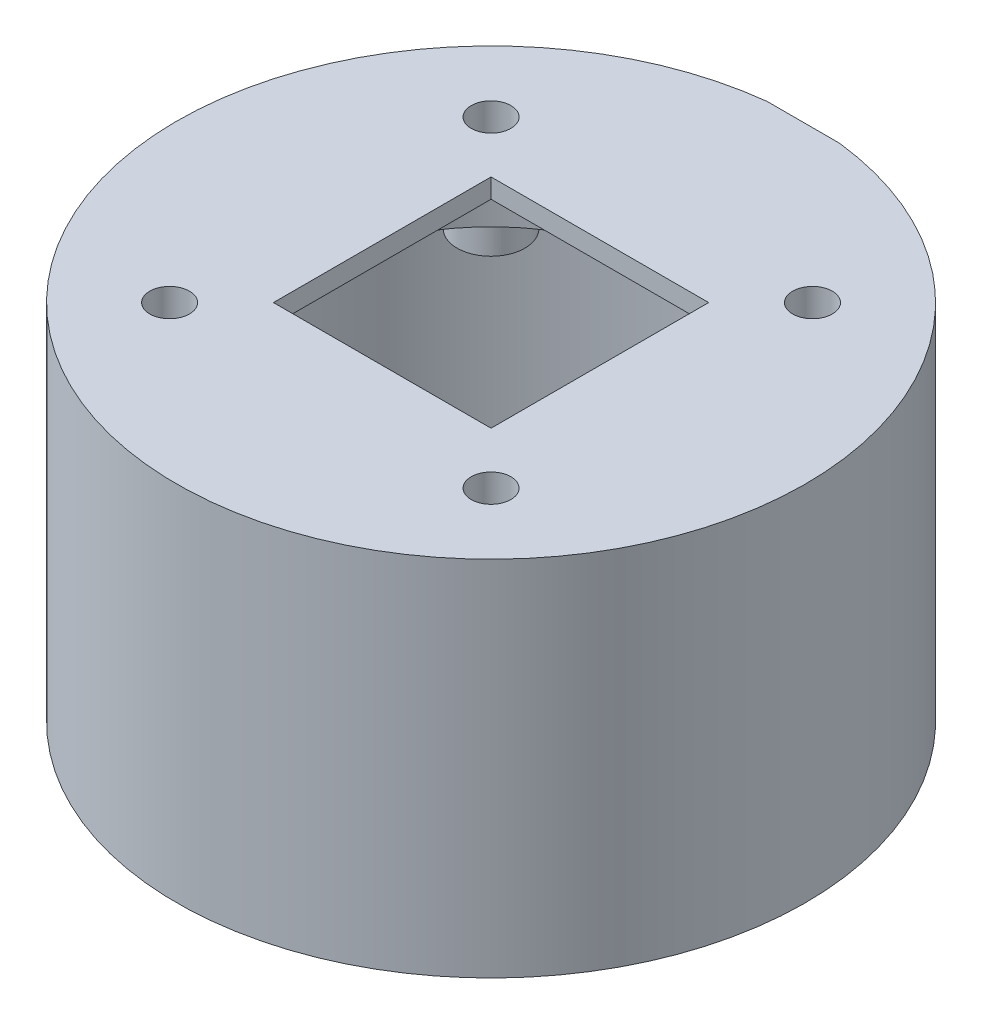
from build123d import *

# Parameters (mm, degrees)
SKETCH1_R               = 65
SKETCH1_R_2             = 60
BOSS_EXTRUDE1_DEPTH     = 55
SKETCH2_R               = 65
BOSS_EXTRUDE2_DEPTH     = 20
SKETCH3_R               = 4.1
SKETCH3_W               = 45
SKETCH3_H               = 45
CUT_EXTRUDE1_DEPTH      = 76
SKETCH5_W               = 45
SKETCH5_H               = 20
CUT_EXTRUDE2_DEPTH      = 18
SKETCH6_R               = 51
CUT_EXTRUDE3_DEPTH      = 6
SKETCH7_R               = 7
SKETCH7_R_2             = 4.1
BOSS_EXTRUDE3_DEPTH     = 6
SKETCH8_R               = 39
CUT_EXTRUDE4_DEPTH      = 10
CUT_EXTRUDE5_DEPTH      = 1
CUT_EXTRUDE5_DEPTH_BACK = 76
SKETCH10_W              = 15
SKETCH10_H              = 12.8
CUT_EXTRUDE6_DEPTH      = 10
CUT_EXTRUDE7_START      = -3
SKETCH11_W              = 20
SKETCH11_H              = 20
CUT_EXTRUDE7_DEPTH      = 10
SKETCH12_R              = 7.5
CUT_EXTRUDE8_DEPTH      = 6
SKETCH13_R              = 10.5
CUT_EXTRUDE9_DEPTH      = 56
CUT_EXTRUDE9_DEPTH_BACK = 6


with BuildPart() as part:
    # Sketch1 → Boss-Extrude1 (new body)
    with BuildSketch(Plane(origin=(0, 0, 0), x_dir=(1, 0, 0), z_dir=(0, 1, 0))):
        with Locations(Location((0, 0, 0), (0, 0, 270))):  # turned: the seam where the file's is
            Circle(SKETCH1_R)
        with Locations(Location((0, 0, 0), (0, 0, 270))):  # turned: the seam where the file's is
            Circle(SKETCH1_R_2, mode=Mode.SUBTRACT)
    extrude(amount=BOSS_EXTRUDE1_DEPTH)

    # Sketch2 → Boss-Extrude2 (add)
    with BuildSketch(Plane(origin=(0, 55, 0), x_dir=(1, 0, 0), z_dir=(0, 1, 0))):
        with Locations(Location((0, 0, 0), (0, 0, 270))):  # turned: the seam where the file's is
            Circle(SKETCH2_R)
    extrude(amount=BOSS_EXTRUDE2_DEPTH)

    # Sketch3 → Cut-Extrude1 (cut, through all)
    with BuildSketch(Plane(origin=(0, 75, 0), x_dir=(1, 0, 0), z_dir=(0, 1, 0))):
        with Locations(Location((-33.234018716, -33.234018716, 0), (0, 0, 270))):  # turned: the seam where the file's is
            Circle(SKETCH3_R)
        with Locations(Location((-33.234018716, 33.234018716, 0), (0, 0, 270))):  # turned: the seam where the file's is
            Circle(SKETCH3_R)
        with Locations(Location((33.234018716, 33.234018716, 0), (0, 0, 270))):  # turned: the seam where the file's is
            Circle(SKETCH3_R)
        with Locations(Location((33.234018716, -33.234018716, 0), (0, 0, 270))):  # turned: the seam where the file's is
            Circle(SKETCH3_R)
        Rectangle(SKETCH3_W, SKETCH3_H)
    extrude(amount=-CUT_EXTRUDE1_DEPTH, mode=Mode.SUBTRACT)

    # Sketch5 → Cut-Extrude2 (cut)
    with BuildSketch(Plane.XZ.offset(-55)):
        with Locations((0, 32.5)):
            Rectangle(SKETCH5_W, SKETCH5_H)
    extrude(amount=-CUT_EXTRUDE2_DEPTH, mode=Mode.SUBTRACT)

    # Sketch6 → Cut-Extrude3 (cut)
    with BuildSketch(Plane.XZ.offset(-55)):
        Circle(SKETCH6_R)
    extrude(amount=-CUT_EXTRUDE3_DEPTH, mode=Mode.SUBTRACT)

    # Sketch7 → Boss-Extrude3 (add)
    with BuildSketch(Plane.XZ.offset(-61)):
        with Locations((-33.234018716, -33.234018716)):
            Circle(SKETCH7_R)
        with Locations(Location((-33.234018716, -33.234018716, 0), (0, 0, 90))):  # turned: the seam where the file's is
            Circle(SKETCH7_R_2, mode=Mode.SUBTRACT)
        with Locations((-33.234018716, 33.234018716)):
            Circle(SKETCH7_R)
        with Locations(Location((-33.234018716, 33.234018716, 0), (0, 0, 90))):  # turned: the seam where the file's is
            Circle(SKETCH7_R_2, mode=Mode.SUBTRACT)
        with Locations((33.234018716, -33.234018716)):
            Circle(SKETCH7_R)
        with Locations(Location((33.234018716, -33.234018716, 0), (0, 0, 90))):  # turned: the seam where the file's is
            Circle(SKETCH7_R_2, mode=Mode.SUBTRACT)
        with Locations((33.234018716, 33.234018716)):
            Circle(SKETCH7_R)
        with Locations(Location((33.234018716, 33.234018716, 0), (0, 0, 90))):  # turned: the seam where the file's is
            Circle(SKETCH7_R_2, mode=Mode.SUBTRACT)
    extrude(amount=BOSS_EXTRUDE3_DEPTH)

    # Sketch8 → Cut-Extrude4 (cut)
    with BuildSketch(Plane.XZ.offset(-61)):
        Circle(SKETCH8_R)
    extrude(amount=-CUT_EXTRUDE4_DEPTH, mode=Mode.SUBTRACT)

    # Sketch9 → Cut-Extrude5 (cut, two sides)
    with BuildSketch(Plane.XZ) as cut_extrude5_sk:
        Polygon((314.441485957, -64.565857851), (7.5, -64.565857851), (-7.5, -64.565857851), (-314.441485957, -64.565857851), (-314.441485957, -678.448829765), (314.441485957, -678.448829765), align=None)
    extrude(amount=CUT_EXTRUDE5_DEPTH, mode=Mode.SUBTRACT)
    extrude(cut_extrude5_sk.sketch, amount=-CUT_EXTRUDE5_DEPTH_BACK, mode=Mode.SUBTRACT)

    # Sketch10 → Cut-Extrude6 (cut)
    with BuildSketch(Plane(origin=(0, 0, -64.565857851), x_dir=(-1, 0, 0), z_dir=(0, 0, -1))):
        with Locations((0, 14)):
            Rectangle(SKETCH10_W, SKETCH10_H)
    extrude(amount=-CUT_EXTRUDE6_DEPTH, mode=Mode.SUBTRACT)

    # Sketch11 → Cut-Extrude7 (cut)
    with BuildSketch(Plane(origin=(0, 0, -64.565857851), x_dir=(-1, 0, 0), z_dir=(0, 0, -1)).offset(CUT_EXTRUDE7_START)):
        with Locations((0, 14)):
            Rectangle(SKETCH11_W, SKETCH11_H)
    extrude(amount=-CUT_EXTRUDE7_DEPTH, mode=Mode.SUBTRACT)

    # Sketch12 → Cut-Extrude8 (cut)
    with BuildSketch(Plane.XZ.offset(-55)):
        with Locations((0, 51)):
            Circle(SKETCH12_R)
    extrude(amount=-CUT_EXTRUDE8_DEPTH, mode=Mode.SUBTRACT)

    # Sketch13 → Cut-Extrude9 (cut, two sides)
    with BuildSketch(Plane.XZ.offset(-55)) as cut_extrude9_sk:
        with Locations((-51, 0)):
            Circle(SKETCH13_R)
    extrude(amount=CUT_EXTRUDE9_DEPTH, mode=Mode.SUBTRACT)
    extrude(cut_extrude9_sk.sketch, amount=-CUT_EXTRUDE9_DEPTH_BACK, mode=Mode.SUBTRACT)


solid = part.part
